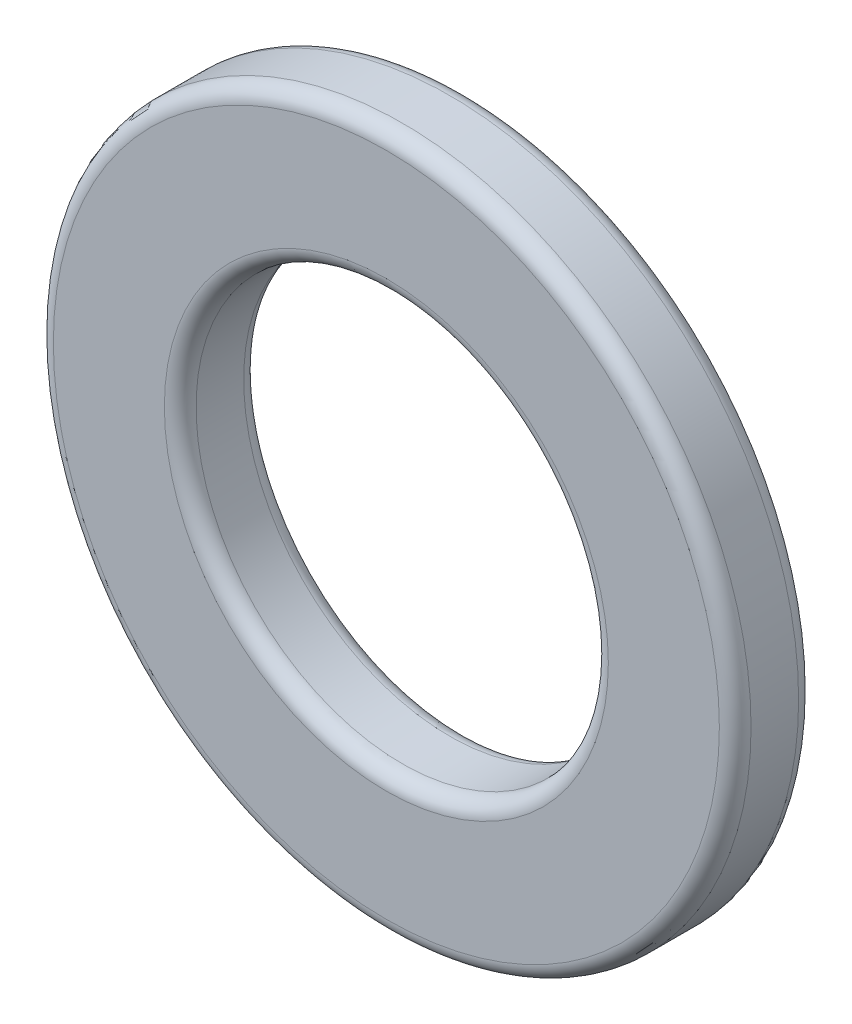
from build123d import *

# Parameters (mm, degrees)
SKETCH1_R           = 11
SKETCH1_R_2         = 6.5
BOSS_EXTRUDE1_DEPTH = 2.5
FILLET1_R           = 0.5


with BuildPart() as part:
    # Sketch1 → Boss-Extrude1 (new body)
    with BuildSketch(Plane.XY):
        Circle(SKETCH1_R)
        Circle(SKETCH1_R_2, mode=Mode.SUBTRACT)
    extrude(amount=BOSS_EXTRUDE1_DEPTH)

    # Fillet1
    fillet1_edges = [part.edges().sort_by_distance(p)[0] for p in [
        (-11, 0, 0),
        (-11, 0, 2.5),
        (-6.5, 0, 0),
        (-6.5, 0, 2.5),
    ]]
    fillet(fillet1_edges, radius=FILLET1_R)


solid = part.part
